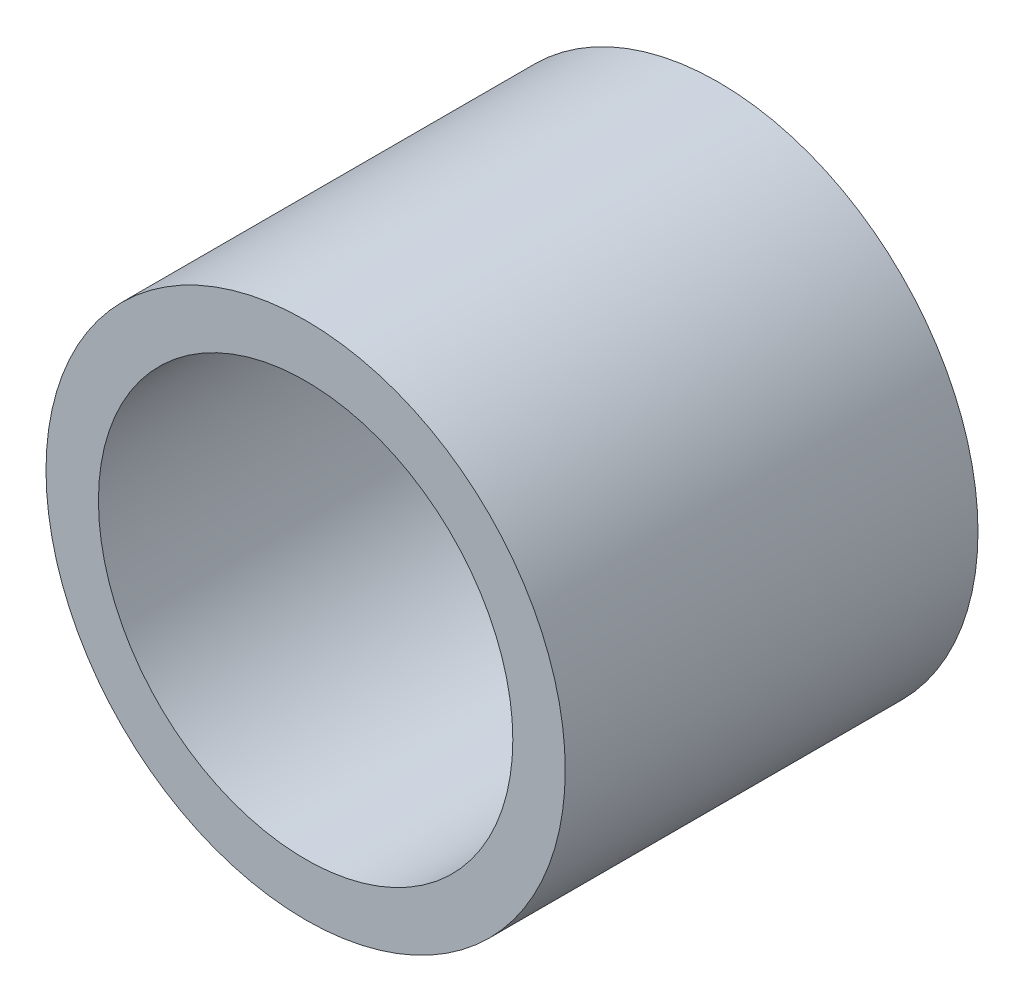
from build123d import *

# Parameters (mm, degrees)
SKETCH5_R           = 3.99415
SKETCH5_R_2         = 3.1877
BOSS_EXTRUDE1_DEPTH = 3.175


with BuildPart() as part:
    # Sketch5 → Boss-Extrude1 (new body, symmetric)
    with BuildSketch(Plane.XY):
        Circle(SKETCH5_R)
        Circle(SKETCH5_R_2, mode=Mode.SUBTRACT)
    extrude(amount=BOSS_EXTRUDE1_DEPTH, both=True)


solid = part.part
